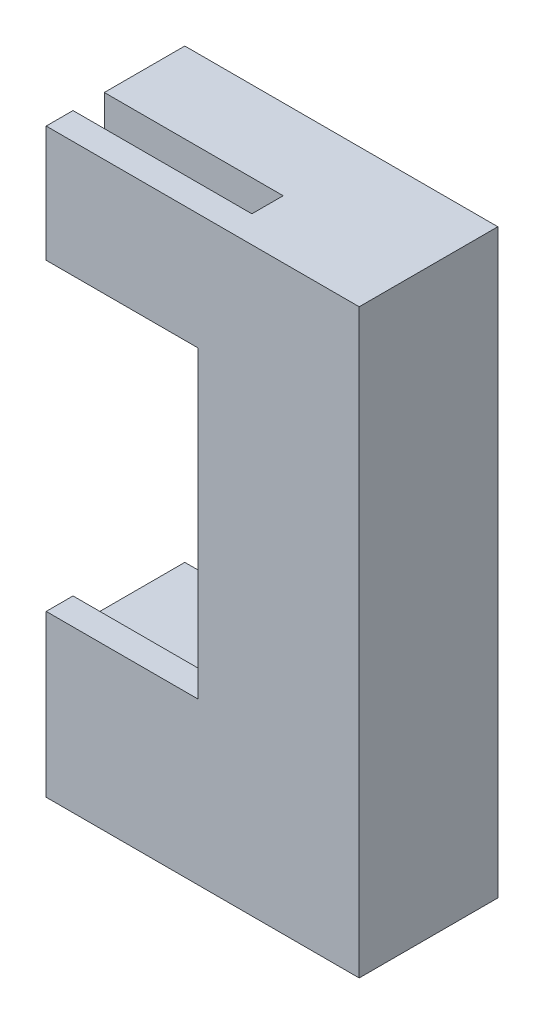
from build123d import *

# Parameters (mm, degrees)
BOSS_EXTRUDE1_DEPTH = 12.5
SKETCH2_W           = 20
SKETCH2_H           = 3.5
CUT_EXTRUDE1_DEPTH  = 10
BOSS_EXTRUDE2_DEPTH = 3
SKETCH4_R           = 2.5
CUT_EXTRUDE2_DEPTH  = 5
SKETCH5_W           = 4
SKETCH5_H           = 2.2
BOSS_EXTRUDE3_DEPTH = 4


with BuildPart() as part:
    # Sketch1 → Boss-Extrude1 (new body)
    with BuildSketch(Plane.XY):
        Polygon((0, 0), (0, 65), (-35, 65), (-35, 55), (-15, 55), (-15, 15), (-35, 15), (-35, 0), align=None)
    extrude(amount=BOSS_EXTRUDE1_DEPTH)

    # Sketch2 → Cut-Extrude1 (cut)
    with BuildSketch(Plane(origin=(0, 65, 0), x_dir=(1, 0, 0), z_dir=(0, 1, 0))):
        with Locations((-25, -10.75)):
            Rectangle(SKETCH2_W, SKETCH2_H)
    extrude(amount=-CUT_EXTRUDE1_DEPTH, mode=Mode.SUBTRACT)

    # Sketch3 → Boss-Extrude2 (add)
    with BuildSketch(Plane.XY.offset(12.5)):
        Polygon((-35, 0), (0, 0), (0, 65), (-35, 65), (-35, 52), (-18, 52), (-18, 18), (-35, 18), align=None)
    extrude(amount=BOSS_EXTRUDE2_DEPTH)

    # Sketch4 → Cut-Extrude2 (cut)
    with BuildSketch(Plane.ZY.offset(35)):
        with Locations((5, 10)):
            Circle(SKETCH4_R)
    extrude(amount=-CUT_EXTRUDE2_DEPTH, mode=Mode.SUBTRACT)

    # Sketch5 → Boss-Extrude3 (add)
    with BuildSketch(Plane.ZY.offset(15)):
        with Locations((2, 17.8)):
            Rectangle(SKETCH5_W, SKETCH5_H)
        with Locations((2, 52.2)):
            Rectangle(SKETCH5_W, SKETCH5_H)
    extrude(amount=BOSS_EXTRUDE3_DEPTH)


solid = part.part
